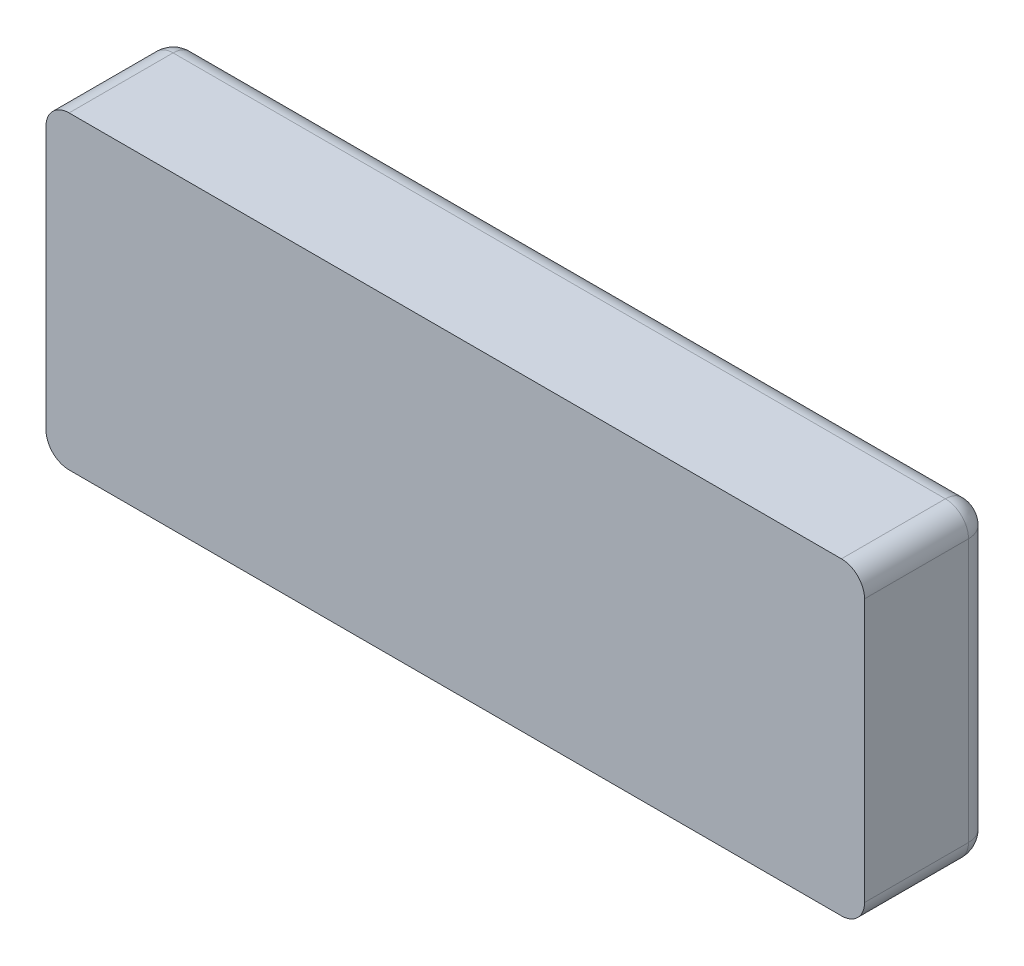
from build123d import *

# Parameters (mm, degrees)
SKETCH1_W           = 90
SKETCH1_H           = 34
BOSS_EXTRUDE1_DEPTH = 13.97
FILLET1_R           = 2.54


with BuildPart() as part:
    # Sketch1 → Boss-Extrude1 (new body)
    with BuildSketch(Plane.XY):
        Rectangle(SKETCH1_W, SKETCH1_H)
    extrude(amount=BOSS_EXTRUDE1_DEPTH)

    # Fillet1
    fillet1_edges = [part.edges().sort_by_distance(p)[0] for p in [
        (0, -17, 0),
        (-45, 0, 0),
        (0, 17, 0),
        (45, 0, 0),
        (45, -17, 6.985),
        (-45, -17, 6.985),
        (-45, 17, 6.985),
        (45, 17, 6.985),
    ]]
    fillet(fillet1_edges, radius=FILLET1_R)


solid = part.part
